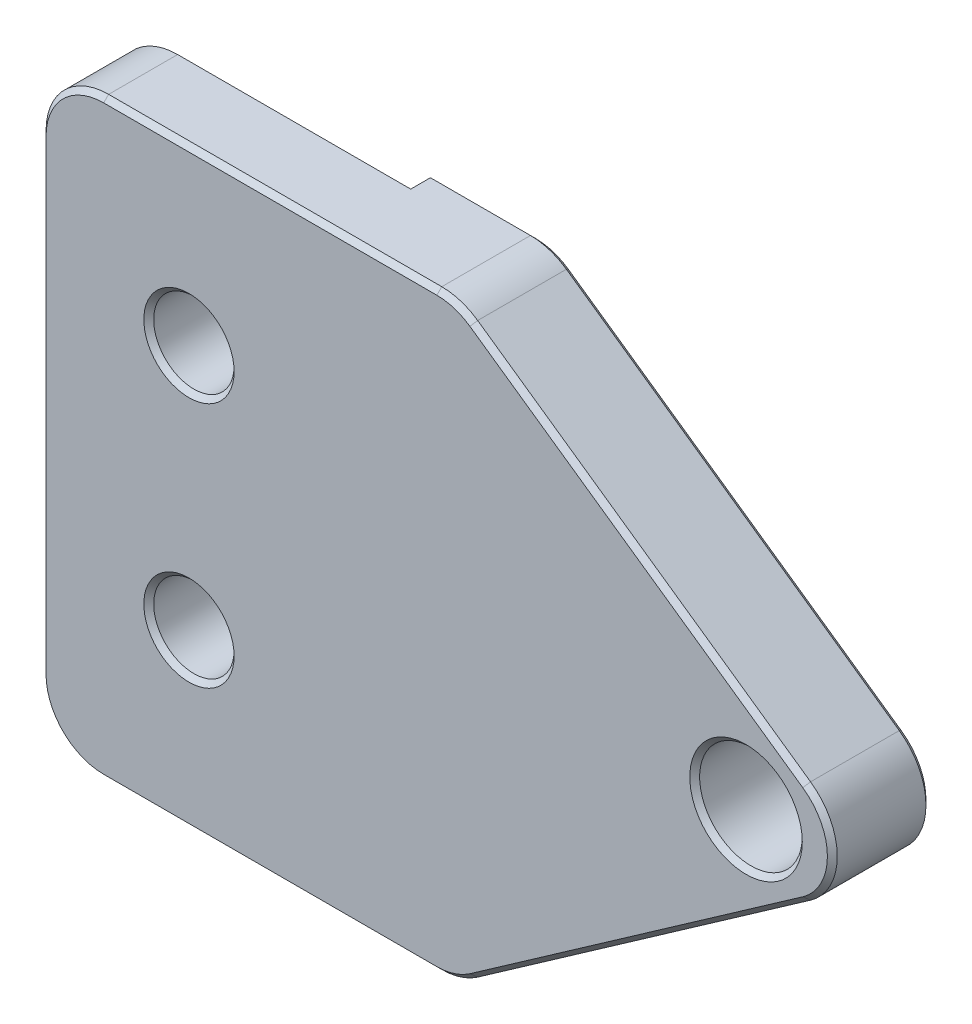
from build123d import *

# Parameters (mm, degrees)
EXTRUDE1_DEPTH                  = 4
SKETCH2_W                       = 12
SKETCH2_H                       = 1
EXTRUDE2_DEPTH                  = 25
F_4_CLEARANCE_HOLE1_D           = 3.2639
F_4_CLEARANCE_HOLE1_DEPTH       = 8.382
F_4_CLEARANCE_HOLE1_TIP         = 0.980574487
F_8_32_TAPPED_HOLE1_D           = 3.4544
F_8_32_TAPPED_HOLE1_DEPTH       = 10.7188
F_8_32_TAPPED_HOLE1_CBORE_D     = 4.1656
F_8_32_TAPPED_HOLE1_CBORE_DEPTH = 8.3312
F_8_32_TAPPED_HOLE1_TIP         = 1.037806461
FILLET1_R                       = 2.54
CHAMFER1_SIZE                   = 0.2


with BuildPart() as part:
    # Sketch1 → Extrude1 (new body)
    with BuildSketch(Plane.XY):
        Polygon((0, 0), (-17.137776081, 12), (-34, 12), (-34, 0), (-34, -12), (-17.137776081, -12), align=None)
    extrude(amount=EXTRUDE1_DEPTH)

    # Sketch2 → Extrude2 (cut, through all)
    with BuildSketch(Plane(origin=(0, 12, 0), x_dir=(1, 0, 0), z_dir=(0, 1, 0))):
        with Locations((-28, -0.5)):
            Rectangle(SKETCH2_W, SKETCH2_H)
    extrude(amount=-EXTRUDE2_DEPTH, mode=Mode.SUBTRACT)

    # #4 Clearance Hole1
    with Locations(Plane(origin=(-28, 5, 4), x_dir=(1, 0, 0), z_dir=(0, 0, 1))):
        with Locations((0, 0), (0, -10)):
            Hole(F_4_CLEARANCE_HOLE1_D / 2, depth=F_4_CLEARANCE_HOLE1_DEPTH)
            with Locations((0, 0, -(F_4_CLEARANCE_HOLE1_DEPTH + F_4_CLEARANCE_HOLE1_TIP / 2))):  # 118° drill point
                Cone(0, F_4_CLEARANCE_HOLE1_D / 2, F_4_CLEARANCE_HOLE1_TIP, mode=Mode.SUBTRACT)

    # #8-32 Tapped Hole1
    with Locations(Plane(origin=(-5.39, 0, 4), x_dir=(1, 0, 0), z_dir=(0, 0, 1))):
        with Locations((0, 0)):
            CounterBoreHole(F_8_32_TAPPED_HOLE1_D / 2, F_8_32_TAPPED_HOLE1_CBORE_D / 2, F_8_32_TAPPED_HOLE1_CBORE_DEPTH, depth=F_8_32_TAPPED_HOLE1_DEPTH)
            with Locations((0, 0, -(F_8_32_TAPPED_HOLE1_DEPTH + F_8_32_TAPPED_HOLE1_TIP / 2))):  # 118° drill point
                Cone(0, F_8_32_TAPPED_HOLE1_D / 2, F_8_32_TAPPED_HOLE1_TIP, mode=Mode.SUBTRACT)

    # Fillet1
    fillet1_edges = [part.edges().sort_by_distance(p)[0] for p in [
        (-17.137776081, -12, 2),
        (-34, -12, 2.5),
        (-34, 12, 2.5),
        (-17.137776081, 12, 2),
        (0, 0, 2),
    ]]
    fillet(fillet1_edges, radius=FILLET1_R)

    # Chamfer1
    chamfer1_edges = [part.edges().sort_by_distance(p)[0] for p in [
        (-19.969317502, -12, 0),
        (-26.36805, -5, 4),
        (-26.36805, 5, 4),
        (-7.4728, 0, 4),
        (-24.699317502, -12, 4),
        (-34, 0, 4),
        (-9.726610784, -6.810646192, 4),
        (-9.726610784, 6.810646192, 4),
        (-24.699317502, 12, 4),
        (-33.256051224, 11.256051224, 4),
        (-17.174842274, 11.882441055, 4),
        (-1.888354861, 0, 4),
        (-17.174842274, -11.882441055, 4),
        (-33.256051224, -11.256051224, 4),
        (-9.726610784, -6.810646192, 0),
        (-19.969317502, 12, 0),
        (-9.726610784, 6.810646192, 0),
        (-17.174842274, 11.882441055, 0),
        (-1.888354861, 0, 0),
        (-17.174842274, -11.882441055, 0),
    ]]
    chamfer(chamfer1_edges, length=CHAMFER1_SIZE)


solid = part.part
